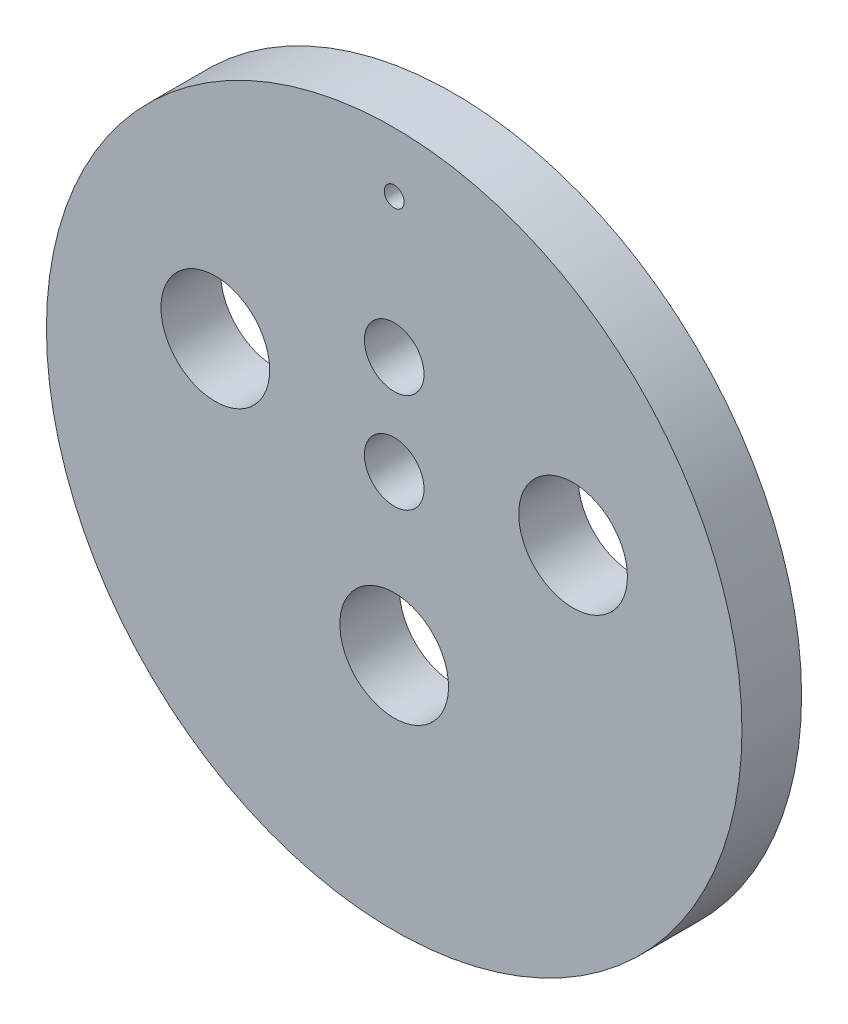
from build123d import *

# Parameters (mm, degrees)
SKETCH1_R           = 17.5
BOSS_EXTRUDE1_DEPTH = 3
SKETCH2_R           = 2.735
SKETCH2_R_2         = 0.5
CUT_EXTRUDE1_DEPTH  = 3
SKETCH3_R           = 1.5
CUT_EXTRUDE2_DEPTH  = 3


with BuildPart() as part:
    # Sketch1 → Boss-Extrude1 (new body)
    with BuildSketch(Plane.XY):
        Circle(SKETCH1_R)
    extrude(amount=BOSS_EXTRUDE1_DEPTH)

    # Sketch2 → Cut-Extrude1 (cut)
    with BuildSketch(Plane.XY.offset(3)):
        with Locations((0, -5.5)):
            Circle(SKETCH2_R)
        with Locations((0, 14.5)):
            Circle(SKETCH2_R_2)
        with Locations((-9, 3.8)):
            Circle(SKETCH2_R)
        with Locations((9, 3.8)):
            Circle(SKETCH2_R)
    extrude(amount=-CUT_EXTRUDE1_DEPTH, mode=Mode.SUBTRACT)

    # Sketch3 → Cut-Extrude2 (cut)
    with BuildSketch(Plane.XY.offset(3)):
        with Locations((0, 7.5)):
            Circle(SKETCH3_R)
        with Locations((0, 2.5)):
            Circle(SKETCH3_R)
    extrude(amount=-CUT_EXTRUDE2_DEPTH, mode=Mode.SUBTRACT)


solid = part.part
